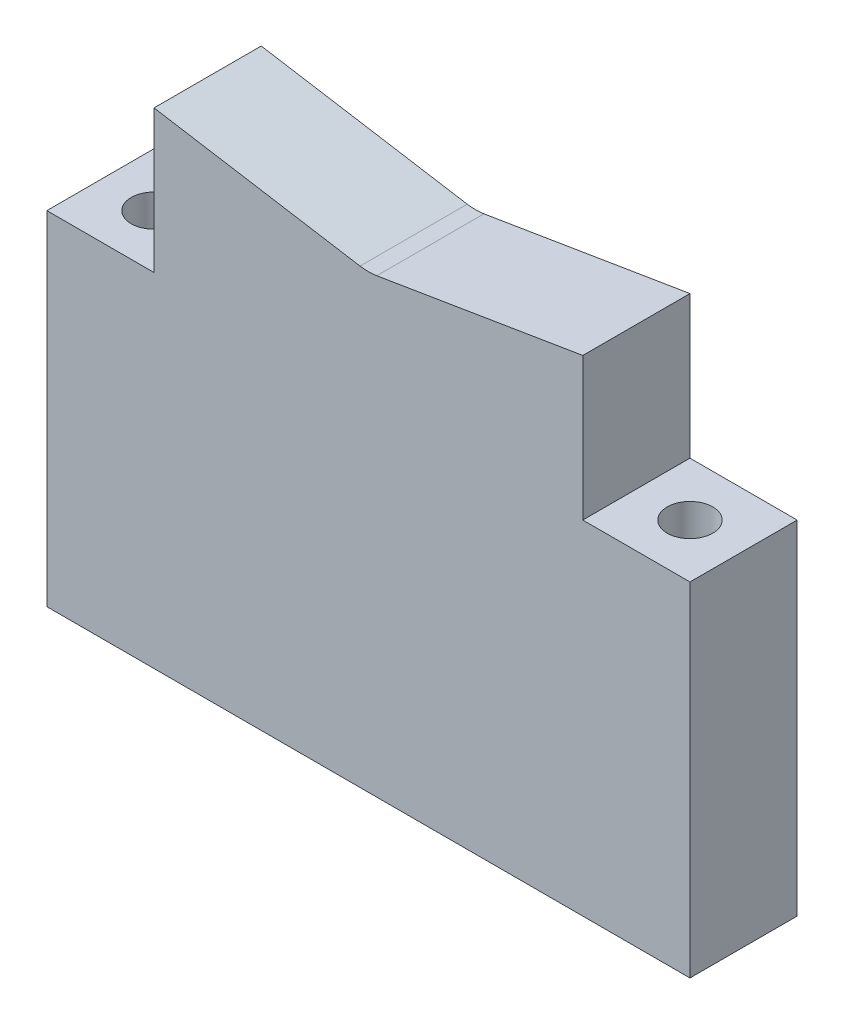
from build123d import *

# Parameters (mm, degrees)
BOSS_EXTRUDE1_DEPTH                = 15.875
F_1_4_CLEARANCE_HOLE1_D            = 6.7564
F_1_16_0_0625_DIAMETER_HOLE1_D     = 11.43
F_1_16_0_0625_DIAMETER_HOLE1_DEPTH = 33.3756
FILLET1_R                          = 7.62


with BuildPart() as part:
    # Sketch1 → Boss-Extrude1 (new body)
    with BuildSketch(Plane.XY):
        Polygon((31.75, 31.75), (-31.75, 31.75), (-31.75, 19.05), (-47.625, 19.05), (-47.625, -31.75), (47.625, -31.75), (47.625, 19.05), (31.75, 19.05), align=None)
        Polygon((-31.75, 40.162272173), (-31.75, 31.75), (31.75, 31.75), (31.75, 40.162272173), (19.119534727, 38.078833297), (0, 34.925), (-19.119537229, 38.07883371), align=None)
    extrude(amount=BOSS_EXTRUDE1_DEPTH)

    # 1/4 Clearance Hole1 (through all)
    with Locations(Plane(origin=(0, 19.05, 0), x_dir=(-1, 0, 0), z_dir=(0, 1, 0))):
        with Locations((39.6875, 7.9375), (-39.6875, 7.9375)):
            Hole(F_1_4_CLEARANCE_HOLE1_D / 2)

    # 1/16 (0.0625) Diameter Hole1
    with Locations(Plane.XZ.offset(31.75)):
        with Locations((39.6875, 7.9375), (-39.6875, 7.9375)):
            Hole(F_1_16_0_0625_DIAMETER_HOLE1_D / 2, depth=F_1_16_0_0625_DIAMETER_HOLE1_DEPTH)

    # Fillet1
    fillet1_edges = [part.edges().sort_by_distance(p)[0] for p in [
        (0, 34.925, 7.9375),
    ]]
    fillet(fillet1_edges, radius=FILLET1_R)


solid = part.part
